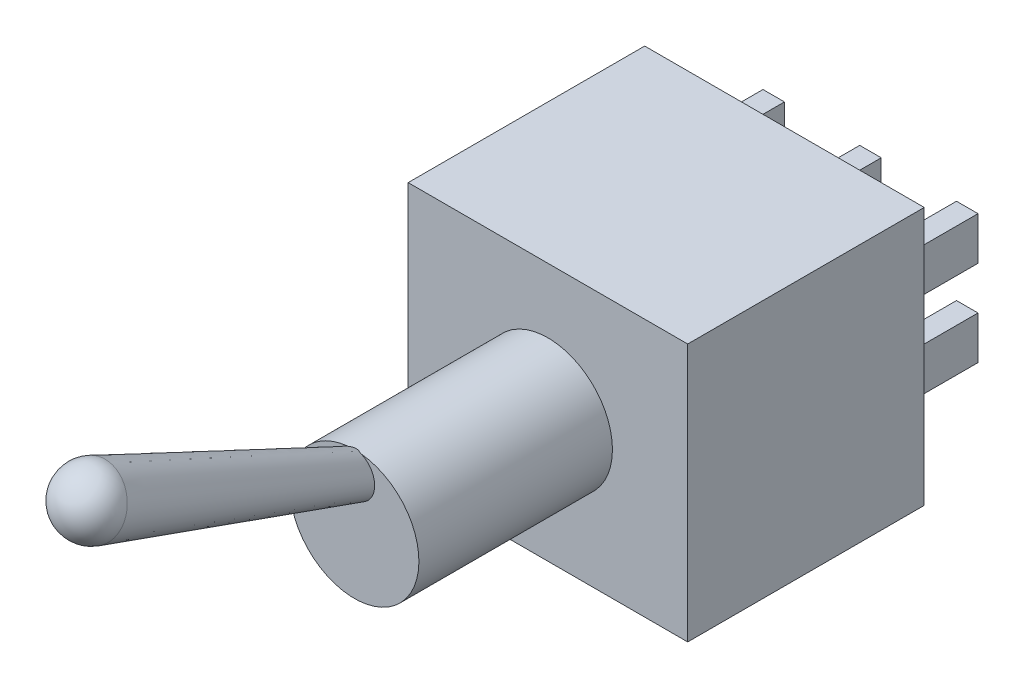
from build123d import *

# Parameters (mm, degrees)
SKETCH1_W           = 12
SKETCH1_H           = 13
BOSS_EXTRUDE1_DEPTH = 11
SKETCH2_W           = 2
SKETCH2_H           = 1
BOSS_EXTRUDE2_DEPTH = 4
SKETCH3_R           = 3
BOSS_EXTRUDE3_DEPTH = 9


with BuildPart() as part:
    # Sketch1 → Boss-Extrude1 (new body)
    with BuildSketch(Plane(origin=(0, 0, 0), x_dir=(0, 1, 0), z_dir=(0, 0, 1))):
        with Locations((6, 6.5)):
            Rectangle(SKETCH1_W, SKETCH1_H)
    extrude(amount=BOSS_EXTRUDE1_DEPTH)

    # Sketch2 → Boss-Extrude2 (add)
    with BuildSketch(Plane(origin=(0, 0, 0), x_dir=(0, 1, 0), z_dir=(0, 0, 1))):
        with Locations((4, 6.5)):
            Rectangle(SKETCH2_W, SKETCH2_H)
        with Locations((8, 6.5)):
            Rectangle(SKETCH2_W, SKETCH2_H)
        with Locations((4, 11)):
            Rectangle(SKETCH2_W, SKETCH2_H)
        with Locations((8, 11)):
            Rectangle(SKETCH2_W, SKETCH2_H)
        with Locations((4, 2)):
            Rectangle(SKETCH2_W, SKETCH2_H)
        with Locations((8, 2)):
            Rectangle(SKETCH2_W, SKETCH2_H)
    extrude(amount=-BOSS_EXTRUDE2_DEPTH)

    # Sketch3 → Boss-Extrude3 (add)
    with BuildSketch(Plane.XY.offset(11)):
        with Locations((-6.5, 6)):
            Circle(SKETCH3_R)
    extrude(amount=BOSS_EXTRUDE3_DEPTH)

    # Sketch4 → Revolve1 (revolve)
    with BuildSketch(Plane.YZ.offset(-6.5)):
        with BuildLine():
            Line((7, 20), (11.637183322, 32.740556467))
            ThreePointArc((11.637183322, 32.740556467), (12.442602218, 33.600493471), (13.620747402, 33.613345551))
            Line((13.620747402, 33.613345551), (8, 20))
            Line((8, 20), (7, 20))
        make_face()
    revolve(axis=Axis((-6.5, 8, 20), (0, 0.381635087, 0.924313075)))


solid = part.part
